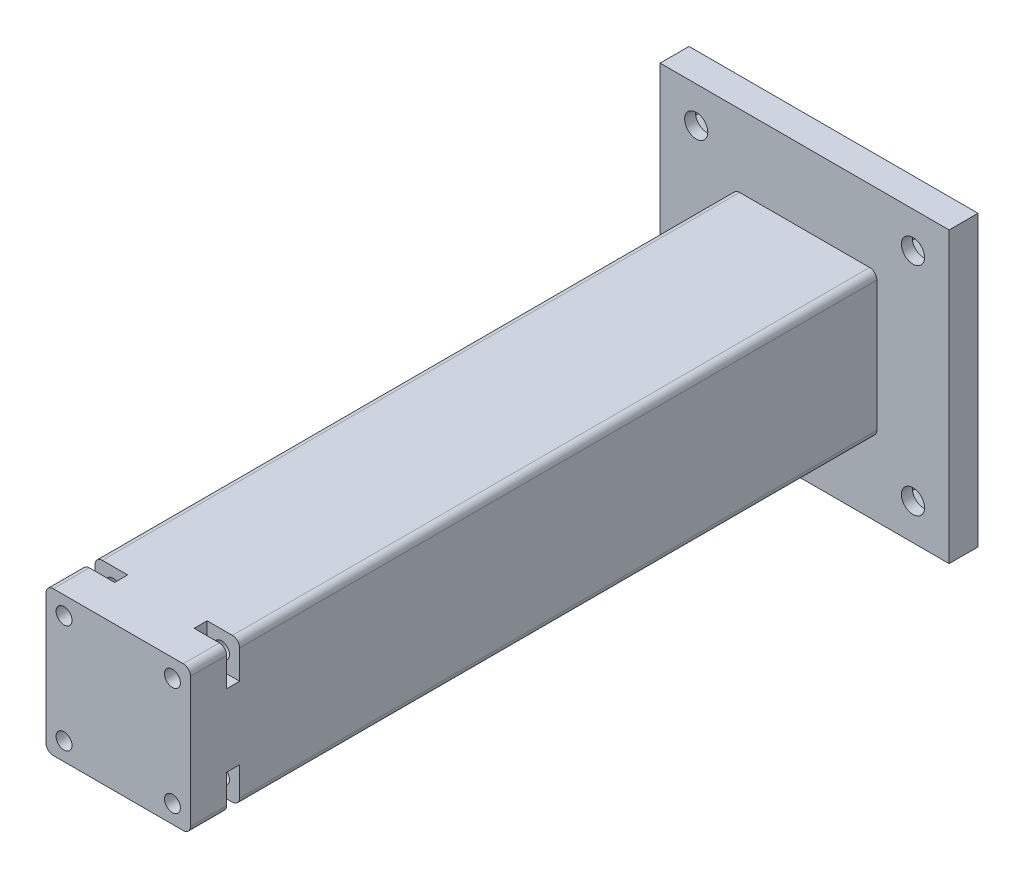
from build123d import *

# Parameters (mm, degrees)
ESQUISSE1_W             = 40
ESQUISSE1_H             = 40
BOSS_EXTRU_1_DEPTH      = 4
ESQUISSE4_W             = 20
ESQUISSE4_H             = 20
BOSS_EXTRU_4_DEPTH      = 95
CONG_3_R                = 1
ESQUISSE5_R             = 1.1
ENL_V_MAT_EXTRU_1_DEPTH = 20
ESQUISSE6_W             = 4.5
ESQUISSE6_H             = 1.8
ENL_V_MAT_EXTRU_2_DEPTH = 5
ESQUISSE7_R             = 1.6
ENL_V_MAT_EXTRU_3_DEPTH = 4
ENL_V_MAT_EXTRU_4_DEPTH = 2.5


with BuildPart() as part:
    # Esquisse1 → Boss.-Extru.1 (new body)
    with BuildSketch(Plane.XY):
        Rectangle(ESQUISSE1_W, ESQUISSE1_H)
    extrude(amount=BOSS_EXTRU_1_DEPTH)

    # Esquisse4 → Boss.-Extru.4 (add)
    with BuildSketch(Plane.XY.offset(4)):
        Rectangle(ESQUISSE4_W, ESQUISSE4_H)
    extrude(amount=BOSS_EXTRU_4_DEPTH)

    # Congé3
    cong_3_edges = [part.edges().sort_by_distance(p)[0] for p in [
        (-10, 10, 51.5),
        (-10, -10, 51.5),
        (10, -10, 51.5),
        (10, 10, 51.5),
    ]]
    fillet(cong_3_edges, radius=CONG_3_R)

    # Esquisse5 → Enlèv. mat.-Extru.1 (cut)
    with BuildSketch(Plane.XY.offset(99)):
        with Locations((7.5, 7.5)):
            Circle(ESQUISSE5_R)
        with Locations((-7.5, 7.5)):
            Circle(ESQUISSE5_R)
        with Locations((-7.5, -7.5)):
            Circle(ESQUISSE5_R)
        with Locations((7.5, -7.5)):
            Circle(ESQUISSE5_R)
    extrude(amount=-ENL_V_MAT_EXTRU_1_DEPTH, mode=Mode.SUBTRACT)

    # Esquisse6 → Enlèv. mat.-Extru.2 (cut)
    with BuildSketch(Plane.XZ.offset(10)):
        with Locations((-7.75, 93.1)):
            Rectangle(ESQUISSE6_W, ESQUISSE6_H)
        with Locations((7.75, 93.1)):
            Rectangle(ESQUISSE6_W, ESQUISSE6_H)
    enl_v_mat_extru_2 = extrude(amount=-ENL_V_MAT_EXTRU_2_DEPTH, mode=Mode.SUBTRACT)

    # Symétrie1: Enlèv. mat.-Extru.2 across plane
    add(enl_v_mat_extru_2.mirror(Plane.ZX), mode=Mode.SUBTRACT)

    # Esquisse7 → Enlèv. mat.-Extru.3 (cut)
    with BuildSketch(Plane(origin=(0, 0, 0), x_dir=(-1, 0, 0), z_dir=(0, 0, -1))):
        with Locations((15, 15)):
            Circle(ESQUISSE7_R)
        with Locations((15, -15)):
            Circle(ESQUISSE7_R)
        with Locations((-15, -15)):
            Circle(ESQUISSE7_R)
        with Locations((-15, 15)):
            Circle(ESQUISSE7_R)
    extrude(amount=-ENL_V_MAT_EXTRU_3_DEPTH, mode=Mode.SUBTRACT)

    # Esquisse8 → Enlèv. mat.-Extru.4 (cut)
    with BuildSketch(Plane(origin=(0, 0, 0), x_dir=(-1, 0, 0), z_dir=(0, 0, -1))):
        Polygon((-11.968911087, 13.25), (-11.968911087, 16.75), (-15, 18.5), (-18.031088913, 16.75), (-18.031088913, 13.25), (-15, 11.5), align=None)
        Polygon((15, 11.5), (18.031088913, 13.25), (18.031088913, 16.75), (15, 18.5), (11.968911087, 16.75), (11.968911087, 13.25), align=None)
        Polygon((15, -18.5), (18.031088913, -16.75), (18.031088913, -13.25), (15, -11.5), (11.968911087, -13.25), (11.968911087, -16.75), align=None)
        Polygon((-11.968911087, -16.75), (-11.968911087, -13.25), (-15, -11.5), (-18.031088913, -13.25), (-18.031088913, -16.75), (-15, -18.5), align=None)
    extrude(amount=-ENL_V_MAT_EXTRU_4_DEPTH, mode=Mode.SUBTRACT)


solid = part.part
